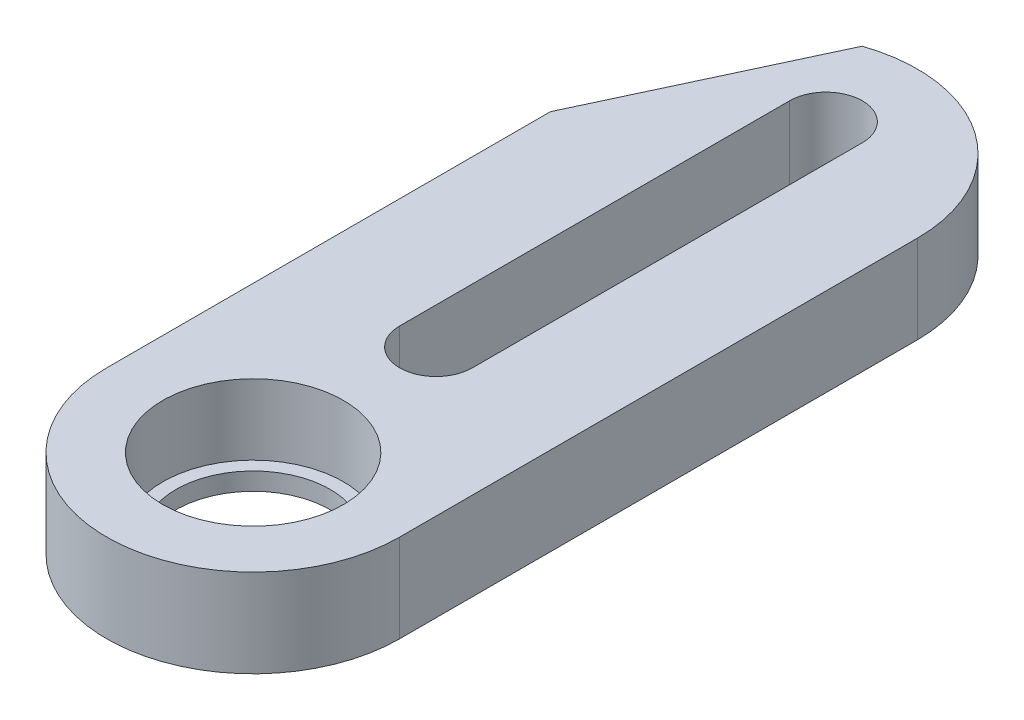
from build123d import *

# Parameters (mm, degrees)
SKETCH1_R           = 6.65
SKETCH1_R_2         = 4.1
BOSS_EXTRUDE1_DEPTH = 4
SKETCH2_R           = 4.1
BOSS_EXTRUDE2_DEPTH = 0.8
SKETCH3_R           = 3.5
CUT_EXTRUDE1_DEPTH  = 1.8
CUT_EXTRUDE2_DEPTH  = 5


with BuildPart() as part:
    # Sketch1 → Boss-Extrude1 (new body)
    with BuildSketch(Plane(origin=(0, 0, 0), x_dir=(1, 0, 0), z_dir=(0, 1, 0))):
        with BuildLine():
            Line((-6.65, 23.5), (-6.65, 0))
            ThreePointArc((-6.65, 0), (-4.702260096, 4.702260094), (-2e-09, 6.65))
            ThreePointArc((-2e-09, 6.65), (4.702260094, 4.702260096), (6.65, 0))
            Line((6.65, 0), (6.65, 23.5))
            ThreePointArc((6.65, 23.5), (0, 30.15), (-6.65, 23.5))
        make_face()
        with BuildLine():
            ThreePointArc((1.65, 8.3), (1.166726188, 7.13327381), (-2e-09, 6.65))
            ThreePointArc((-2e-09, 6.65), (-1.16672619, 7.133273812), (-1.65, 8.3))
            Line((-1.65, 8.3), (-1.65, 26))
            ThreePointArc((-1.65, 26), (0, 27.65), (1.65, 26))
            Line((1.65, 26), (1.65, 8.3))
        make_face(mode=Mode.SUBTRACT)
        Circle(SKETCH1_R)
        Circle(SKETCH1_R_2, mode=Mode.SUBTRACT)
    extrude(amount=BOSS_EXTRUDE1_DEPTH)

    # Sketch2 → Boss-Extrude2 (add)
    with BuildSketch(Plane(origin=(0, 0, 0), x_dir=(1, 0, 0), z_dir=(0, 1, 0))):
        Circle(SKETCH2_R)
    extrude(amount=BOSS_EXTRUDE2_DEPTH)

    # Sketch3 → Cut-Extrude1 (cut, through all)
    with BuildSketch(Plane(origin=(0, 0.8, 0), x_dir=(1, 0, 0), z_dir=(0, 1, 0))):
        Circle(SKETCH3_R)
    extrude(amount=-CUT_EXTRUDE1_DEPTH, mode=Mode.SUBTRACT)

    # Sketch4 → Cut-Extrude2 (cut, through all)
    with BuildSketch(Plane.XZ):
        with BuildLine():
            Line((-6.65, -20.142571947), (-2.15, -29.792853089))
            ThreePointArc((-2.15, -29.792853089), (-5.409251335, -27.368139087), (-6.65, -23.5))
            Line((-6.65, -23.5), (-6.65, -20.142571947))
        make_face()
    extrude(amount=-CUT_EXTRUDE2_DEPTH, mode=Mode.SUBTRACT)


solid = part.part
